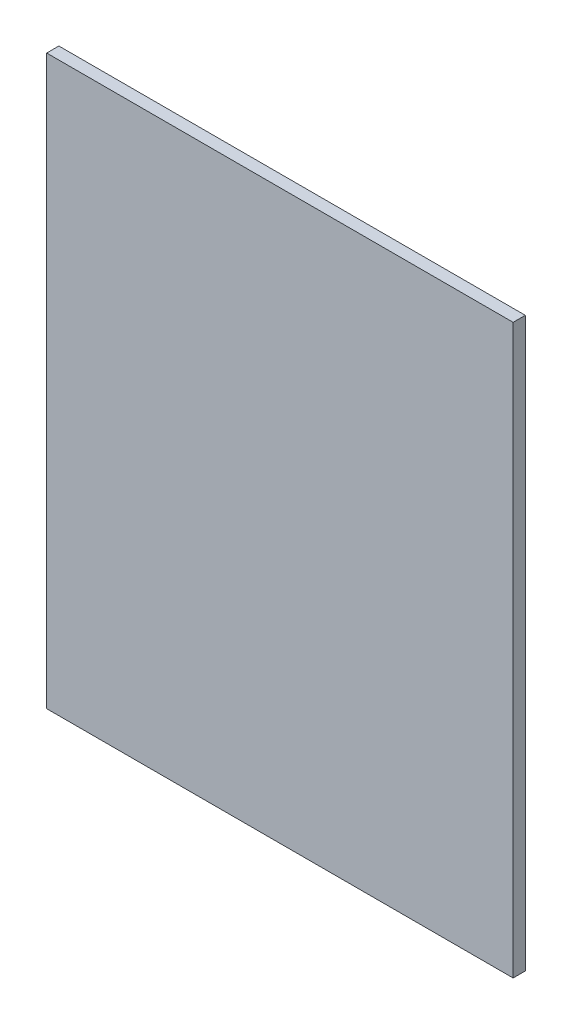
from build123d import *

# Parameters (mm, degrees)
SKETCH2_W           = 115
SKETCH2_H           = 140
BOSS_EXTRUDE1_DEPTH = 3


with BuildPart() as part:
    # Sketch2 → Boss-Extrude1 (new body)
    with BuildSketch(Plane.XY):
        with Locations((94.384088259, -362.926224712)):
            Rectangle(SKETCH2_W, SKETCH2_H)
    extrude(amount=BOSS_EXTRUDE1_DEPTH)


solid = part.part
